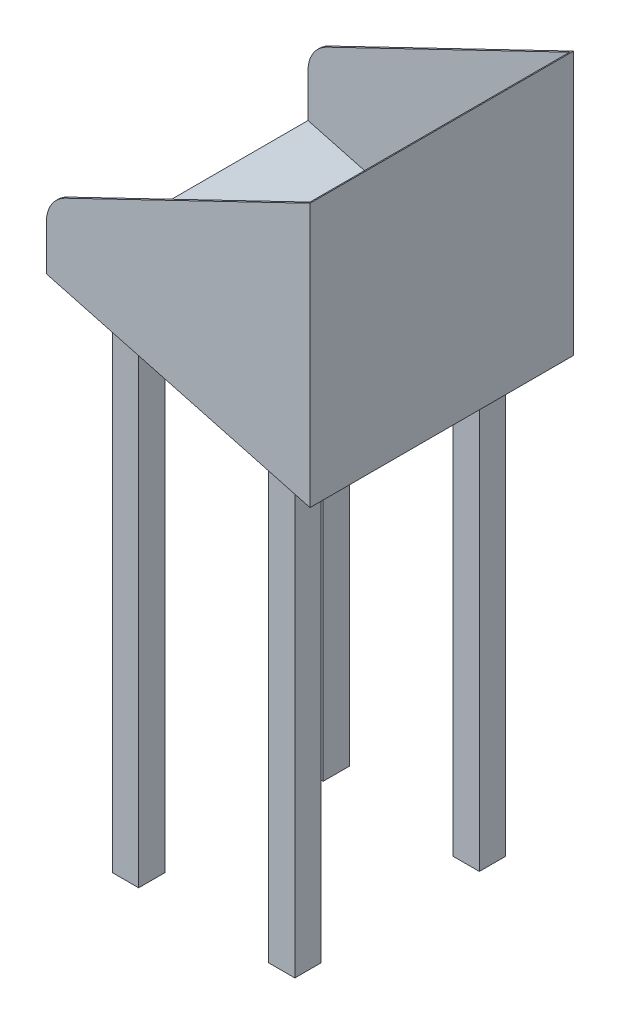
from build123d import *

# Parameters (mm, degrees)
BOSS_EXTRUDE2_DEPTH             = 400
SHELL3_T                        = -3
FILLET2_R                       = 50
FILLET3_R                       = 50
BOSS_EXTRUDE3_REACH             = 1052
SKETCH3_W                       = 40
SKETCH3_H                       = 40
BOSS_EXTRUDE3_DIRECTION_2_DEPTH = 19.71
SKETCH4_R                       = 7.5
CUT_EXTRUDE1_DEPTH              = 20


with BuildPart() as part:
    # Sketch2 → Boss-Extrude2 (new body)
    with BuildSketch(Plane.XY):
        Polygon((0, 400), (0, 0), (-400, 107.179676972), (-400, 207.179676972), align=None)
    extrude(amount=BOSS_EXTRUDE2_DEPTH)

    # Shell3
    shell3_openings = [part.faces().sort_by_distance(p)[0] for p in [
        (-400, 157.179676972, 200),
        (-200, 303.589838486, 200),
    ]]
    offset(amount=SHELL3_T, openings=shell3_openings, kind=Kind.INTERSECTION)

    # Fillet2
    fillet2_edges = [part.edges().sort_by_distance(p)[0] for p in [
        (-400, 207.179676972, 398.5),
    ]]
    fillet(fillet2_edges, radius=FILLET2_R)

    # Fillet3
    fillet3_edges = [part.edges().sort_by_distance(p)[0] for p in [
        (-400, 207.179676972, 1.5),
    ]]
    fillet(fillet3_edges, radius=FILLET3_R)

    # Sketch3 → Boss-Extrude3 (add, up to next)
    with BuildSketch(Plane(origin=(0, -650, 0), x_dir=(1, 0, 0), z_dir=(0, 1, 0)), mode=Mode.PRIVATE) as boss_extrude3_sk1:
        with Locations((-83, -60)):
            Rectangle(SKETCH3_W, SKETCH3_H)
    boss_extrude3_tool1 = extrude(boss_extrude3_sk1.sketch, amount=BOSS_EXTRUDE3_REACH, mode=Mode.PRIVATE) - part.part
    add(boss_extrude3_tool1.solids().sort_by_distance((-83, -650, 60))[0])
    # Sketch3 → Boss-Extrude3 (add, up to next)
    with BuildSketch(Plane(origin=(0, -650, 0), x_dir=(1, 0, 0), z_dir=(0, 1, 0)), mode=Mode.PRIVATE) as boss_extrude3_sk2:
        with Locations((-320, -60)):
            Rectangle(SKETCH3_W, SKETCH3_H)
    boss_extrude3_tool2 = extrude(boss_extrude3_sk2.sketch, amount=BOSS_EXTRUDE3_REACH, mode=Mode.PRIVATE) - part.part
    add(boss_extrude3_tool2.solids().sort_by_distance((-320, -650, 60))[0])
    # Sketch3 → Boss-Extrude3 (add, up to next)
    with BuildSketch(Plane(origin=(0, -650, 0), x_dir=(1, 0, 0), z_dir=(0, 1, 0)), mode=Mode.PRIVATE) as boss_extrude3_sk3:
        with Locations((-83, -340)):
            Rectangle(SKETCH3_W, SKETCH3_H)
    boss_extrude3_tool3 = extrude(boss_extrude3_sk3.sketch, amount=BOSS_EXTRUDE3_REACH, mode=Mode.PRIVATE) - part.part
    add(boss_extrude3_tool3.solids().sort_by_distance((-83, -650, 340))[0])
    # Sketch3 → Boss-Extrude3 (add, up to next)
    with BuildSketch(Plane(origin=(0, -650, 0), x_dir=(1, 0, 0), z_dir=(0, 1, 0)), mode=Mode.PRIVATE) as boss_extrude3_sk4:
        with Locations((-320, -340)):
            Rectangle(SKETCH3_W, SKETCH3_H)
    boss_extrude3_tool4 = extrude(boss_extrude3_sk4.sketch, amount=BOSS_EXTRUDE3_REACH, mode=Mode.PRIVATE) - part.part
    add(boss_extrude3_tool4.solids().sort_by_distance((-320, -650, 340))[0])

    # Sketch3 → Boss-Extrude3 direction 2 (add)
    with BuildSketch(Plane(origin=(0, -650, 0), x_dir=(1, 0, 0), z_dir=(0, 1, 0))):
        with Locations((-83, -60)):
            Rectangle(SKETCH3_W, SKETCH3_H)
        with Locations((-320, -60)):
            Rectangle(SKETCH3_W, SKETCH3_H)
        with Locations((-83, -340)):
            Rectangle(SKETCH3_W, SKETCH3_H)
        with Locations((-320, -340)):
            Rectangle(SKETCH3_W, SKETCH3_H)
    extrude(amount=-BOSS_EXTRUDE3_DIRECTION_2_DEPTH)

    # Sketch4 → Cut-Extrude1 (cut)
    with BuildSketch(Plane.XZ.offset(669.71)):
        with Locations((-320, 340)):
            Circle(SKETCH4_R)
        with Locations((-83, 340)):
            Circle(SKETCH4_R)
        with Locations((-320, 60)):
            Circle(SKETCH4_R)
        with Locations((-83, 60)):
            Circle(SKETCH4_R)
    extrude(amount=-CUT_EXTRUDE1_DEPTH, mode=Mode.SUBTRACT)


solid = part.part
